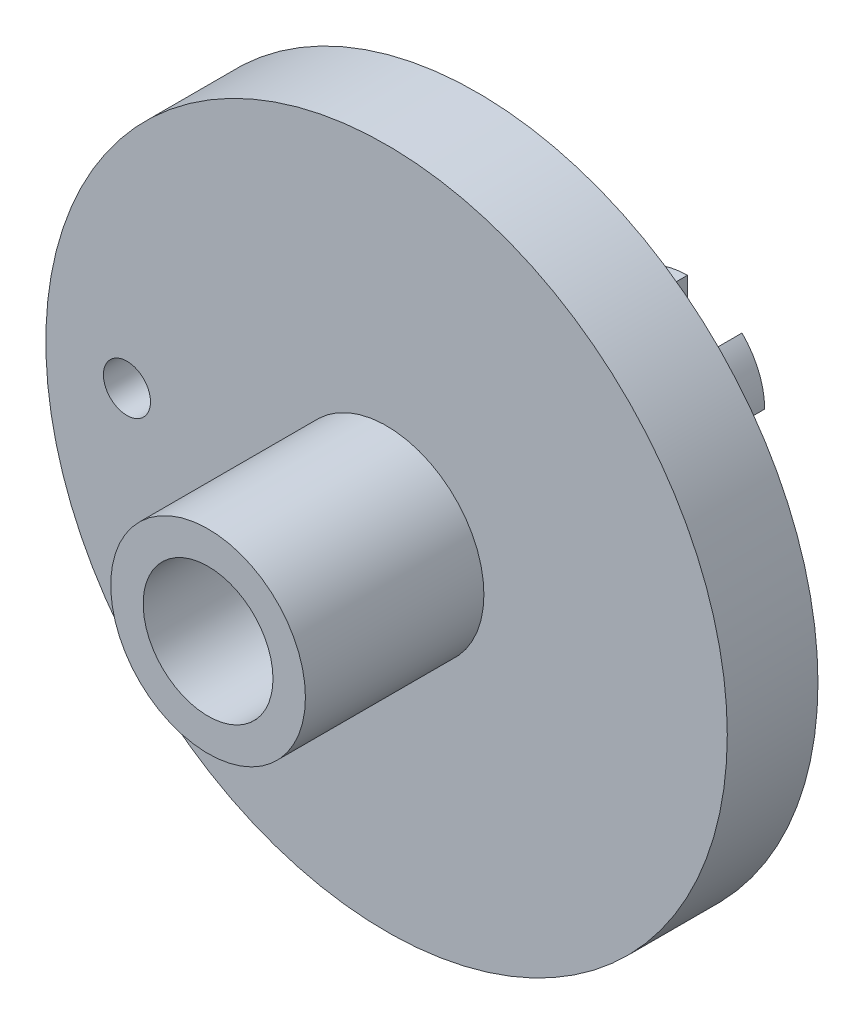
from build123d import *

# Parameters (mm, degrees)
SKETCH1_R           = 4.7625
BOSS_EXTRUDE1_DEPTH = 16
SKETCH2_R           = 21
BOSS_EXTRUDE2_DEPTH = 5.588
BOSS_EXTRUDE3_DEPTH = 2.54
SKETCH6_R           = 1.55
CUT_EXTRUDE1_DEPTH  = 19.54
SKETCH7_R           = 1.45
CUT_EXTRUDE2_DEPTH  = 7.62
SKETCH8_R           = 6
SKETCH8_R_2         = 4
BOSS_EXTRUDE4_DEPTH = 11
FILLET1_R           = 2


with BuildPart() as part:
    # Sketch1 → Boss-Extrude1 (new body)
    with BuildSketch(Plane.XY):
        Circle(SKETCH1_R)
    extrude(amount=-BOSS_EXTRUDE1_DEPTH)

    # Sketch2 → Boss-Extrude2 (add)
    with BuildSketch(Plane.XY):
        Circle(SKETCH2_R)
    extrude(amount=-BOSS_EXTRUDE2_DEPTH)

    # Sketch3 → Boss-Extrude3 (add)
    with BuildSketch(Plane(origin=(0, 0, -16), x_dir=(-1, 0, 0), z_dir=(0, 0, -1))):
        with BuildLine():
            Line((1.979898987, -1.979898987), (3.367596045, -3.367596045))
            ThreePointArc((3.367596045, -3.367596045), (4.399976274, -1.822529847), (4.7625, 0))
            Line((4.7625, 0), (2.8, 0))
            ThreePointArc((2.8, 0), (2.586862691, -1.071513611), (1.979898987, -1.979898987))
        make_face()
        with BuildLine():
            ThreePointArc((-3.367596045, 3.367596045), (-4.399976274, 1.822529847), (-4.7625, 0))
            Line((-4.7625, 0), (-2.8, 0))
            ThreePointArc((-2.8, 0), (-2.586862691, 1.071513611), (-1.979898987, 1.979898987))
            Line((-1.979898987, 1.979898987), (-3.367596045, 3.367596045))
        make_face()
        with BuildLine():
            ThreePointArc((-3.367596045, -3.367596045), (-1.822529847, -4.399976274), (0, -4.7625))
            Line((0, -4.7625), (0, -2.8))
            ThreePointArc((0, -2.8), (-1.071513611, -2.586862691), (-1.979898987, -1.979898987))
            Line((-1.979898987, -1.979898987), (-3.367596045, -3.367596045))
        make_face()
        with BuildLine():
            Line((0, 4.7625), (0, 2.8))
            ThreePointArc((0, 2.8), (1.071513611, 2.586862691), (1.979898987, 1.979898987))
            Line((1.979898987, 1.979898987), (3.367596045, 3.367596045))
            ThreePointArc((3.367596045, 3.367596045), (1.822529847, 4.399976274), (0, 4.7625))
        make_face()
    extrude(amount=BOSS_EXTRUDE3_DEPTH)

    # Sketch6 → Cut-Extrude1 (cut, through all)
    with BuildSketch(Plane.XY):
        Circle(SKETCH6_R)
    extrude(amount=-CUT_EXTRUDE1_DEPTH, mode=Mode.SUBTRACT)

    # Sketch7 → Cut-Extrude2 (cut)
    with BuildSketch(Plane.XY):
        with Locations((-16, 0)):
            Circle(SKETCH7_R)
    extrude(amount=-CUT_EXTRUDE2_DEPTH, mode=Mode.SUBTRACT)

    # Sketch8 → Boss-Extrude4 (add)
    with BuildSketch(Plane.XY):
        Circle(SKETCH8_R)
        Circle(SKETCH8_R_2, mode=Mode.SUBTRACT)
    extrude(amount=BOSS_EXTRUDE4_DEPTH)

    # Fillet1
    fillet1_edges = [part.edges().sort_by_distance(p)[0] for p in [
        (-4.7625, 0, -5.588),
    ]]
    fillet(fillet1_edges, radius=FILLET1_R)


solid = part.part
